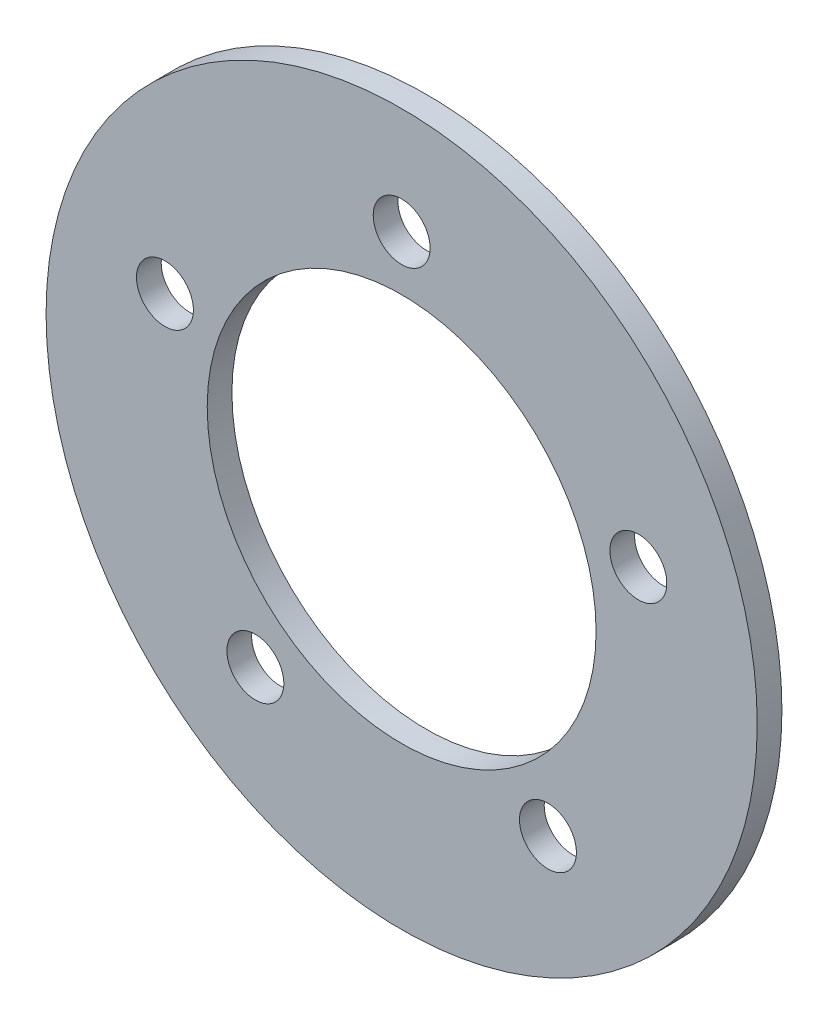
from build123d import *

# Parameters (mm, degrees)
SKETCH1_R           = 22.86
SKETCH1_R_2         = 12.5
SKETCH1_R_3         = 1.8288
BOSS_EXTRUDE1_DEPTH = 1.5875


with BuildPart() as part:
    # Sketch1 → Boss-Extrude1 (new body)
    with BuildSketch(Plane(origin=(0, 0, -12.7), x_dir=(-1, 0, 0), z_dir=(0, 0, -1))):
        Circle(SKETCH1_R)
        Circle(SKETCH1_R_2, mode=Mode.SUBTRACT)
        with Locations((15.216904261, 4.94427191)):
            Circle(SKETCH1_R_3, mode=Mode.SUBTRACT)
        with Locations((9.404564037, -12.94427191)):
            Circle(SKETCH1_R_3, mode=Mode.SUBTRACT)
        with Locations((-9.404564037, -12.94427191)):
            Circle(SKETCH1_R_3, mode=Mode.SUBTRACT)
        with Locations((-15.216904261, 4.94427191)):
            Circle(SKETCH1_R_3, mode=Mode.SUBTRACT)
        with Locations((0, 16)):
            Circle(SKETCH1_R_3, mode=Mode.SUBTRACT)
    extrude(amount=BOSS_EXTRUDE1_DEPTH)


solid = part.part
